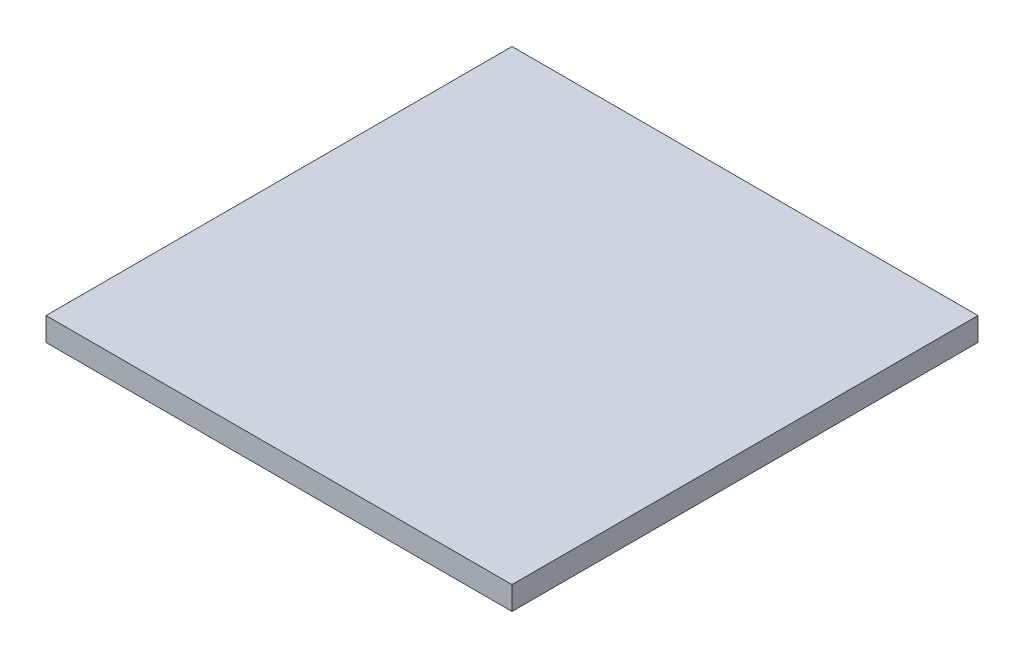
from build123d import *

# Parameters (mm, degrees)
SKETCH3_W           = 60
SKETCH3_H           = 3
BOSS_EXTRUDE3_DEPTH = 60


with BuildPart() as part:
    # Sketch3 → Boss-Extrude3 (new body)
    with BuildSketch(Plane.XY):
        with Locations((30, 1.5)):
            Rectangle(SKETCH3_W, SKETCH3_H)
    extrude(amount=BOSS_EXTRUDE3_DEPTH)


solid = part.part
